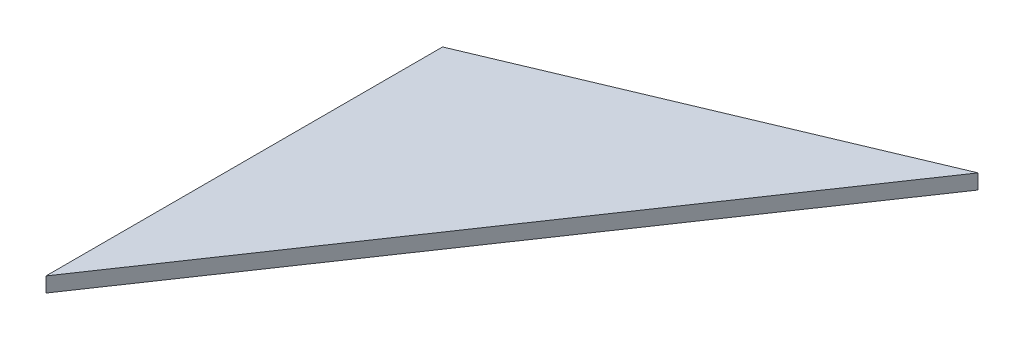
from build123d import *

# Parameters (mm, degrees)
BOSS_EXTRUDE1_DEPTH = 4.7625


with BuildPart() as part:
    # Sketch1 → Boss-Extrude1 (new body)
    with BuildSketch(Plane(origin=(0, 0, 0), x_dir=(1, 0, 0), z_dir=(0, 1, 0))):
        Polygon((0, 0), (0, 127), (120.65, 177.8), align=None)
    extrude(amount=BOSS_EXTRUDE1_DEPTH)


solid = part.part
